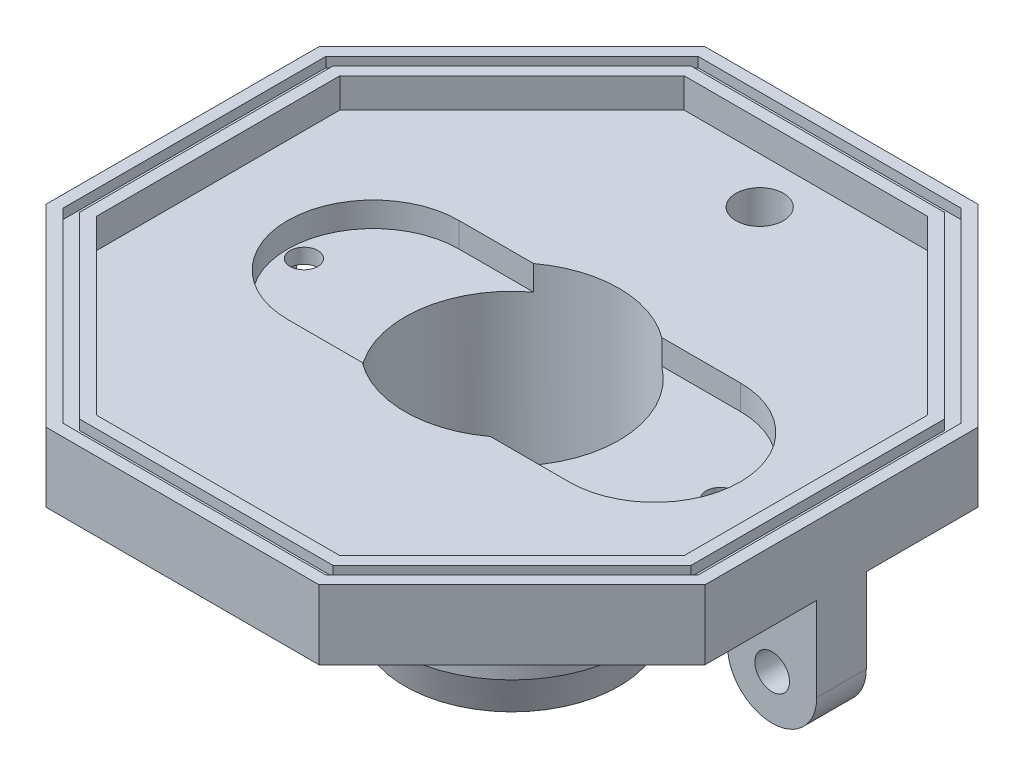
from build123d import *

# Parameters (mm, degrees)
EXTRUDE_1_DEPTH      = 4
SKETCH_2_R           = 2.4
CUT_EXTRUDE_1_DEPTH  = 4
EXTRUDE_3_DEPTH      = 3
CUT_EXTRUDE_2_DEPTH  = 1
SKETCH_7_R           = 10.8
CUT_EXTRUDE_4_DEPTH  = 4
SKETCH_8_R           = 11.8
SKETCH_8_R_2         = 10.8
EXTRUDE_4_DEPTH      = 16.5
SKETCH_9_R           = 10.8
SKETCH_9_R_2         = 6.05
EXTRUDE_5_DEPTH      = 3.5
CUT_EXTRUDE_5_DEPTH  = 2.5
SKETCH_13_W          = 9
SKETCH_13_H          = 5
EXTRUDE_7_DEPTH      = 8.5
SKETCH_16_R          = 1.4
CUT_EXTRUDE_8_DEPTH  = 10
SKETCH_19_ONE_SIDE_W = 4.5
SKETCH_19_ONE_SIDE_H = 5
SKETCH_20_R          = 1.75
CUT_EXTRUDE_9_DEPTH  = 36.75966317


with BuildPart() as part:
    # 스케치1 → 보스-돌출1 (new body)
    with BuildSketch(Plane(origin=(0, 0, 0), x_dir=(1, 0, 0), z_dir=(0, 1, 0))):
        Polygon((13.776603565, -33.25966317), (33.25966317, -13.776603565), (33.25966317, 13.776603565), (13.776603565, 33.25966317), (-13.776603565, 33.25966317), (-33.25966317, 13.776603565), (-33.25966317, -13.776603565), (-13.776603565, -33.25966317), align=None)
    extrude(amount=EXTRUDE_1_DEPTH)

    # 스케치2 → 컷-돌출1 (cut)
    with BuildSketch(Plane.XZ):
        with Locations((0, -25)):
            Circle(SKETCH_2_R)
    extrude(amount=-CUT_EXTRUDE_1_DEPTH, mode=Mode.SUBTRACT)

    # 스케치3 → 보스-돌출3 (add)
    with BuildSketch(Plane(origin=(0, 4, 0), x_dir=(1, 0, 0), z_dir=(0, 1, 0))):
        Polygon((-13.776603565, 33.25966317), (-33.25966317, 13.776603565), (-33.25966317, -13.776603565), (-13.776603565, -33.25966317), (13.776603565, -33.25966317), (33.25966317, -13.776603565), (33.25966317, 13.776603565), (13.776603565, 33.25966317), align=None)
        Polygon((-12.285434741, 29.65966317), (-29.65966317, 12.285434741), (-29.65966317, -12.285434741), (-12.285434741, -29.65966317), (12.285434741, -29.65966317), (29.65966317, -12.285434741), (29.65966317, 12.285434741), (12.285434741, 29.65966317), align=None, mode=Mode.SUBTRACT)
    extrude(amount=EXTRUDE_3_DEPTH)

    # 스케치5 → 컷-돌출2 (cut)
    with BuildSketch(Plane(origin=(0, 7, 0), x_dir=(1, 0, 0), z_dir=(0, 1, 0))):
        Polygon((32.05966317, -13.27954729), (32.05966317, 13.27954729), (13.27954729, 32.05966317), (-13.27954729, 32.05966317), (-32.05966317, 13.27954729), (-32.05966317, -13.27954729), (-13.27954729, -32.05966317), (13.27954729, -32.05966317), align=None)
        Polygon((30.85966317, 12.782491015), (12.782491015, 30.85966317), (-12.782491015, 30.85966317), (-30.85966317, 12.782491015), (-30.85966317, -12.782491015), (-12.782491015, -30.85966317), (12.782491015, -30.85966317), (30.85966317, -12.782491015), align=None, mode=Mode.SUBTRACT)
    extrude(amount=-CUT_EXTRUDE_2_DEPTH, mode=Mode.SUBTRACT)

    # 스케치7 → 컷-돌출4 (cut)
    with BuildSketch(Plane.XZ):
        Circle(SKETCH_7_R)
    extrude(amount=-CUT_EXTRUDE_4_DEPTH, mode=Mode.SUBTRACT)

    # 스케치8 → 보스-돌출4 (add)
    with BuildSketch(Plane.XZ):
        Circle(SKETCH_8_R)
        Circle(SKETCH_8_R_2, mode=Mode.SUBTRACT)
    extrude(amount=EXTRUDE_4_DEPTH)



with BuildPart() as body_2:
    # 스케치9 → 보스-돌출5 (new body)
    with BuildSketch(Plane.XZ.offset(16.5)):
        Circle(SKETCH_9_R)
        Circle(SKETCH_9_R_2, mode=Mode.SUBTRACT)
    extrude(amount=EXTRUDE_5_DEPTH)


with BuildPart() as part_1:
    add(part.part)

    add(body_2.part)  # 회전1 merges body 2
    # 스케치10 → 회전1 (revolve)
    with BuildSketch(Plane.XY):
        Polygon((-11.8, -16.5), (-10.8, -20), (-10.8, -16.5), align=None)
    revolve(axis=Axis((0, -20, 0), (0, 1, 0)))

    # 스케치11 → 컷-돌출5 (cut)
    with BuildSketch(Plane(origin=(0, 4, 0), x_dir=(1, 0, 0), z_dir=(0, 1, 0))):
        with BuildLine():
            Line((-14, 8.65), (14.4, 8.65))
            ThreePointArc((14.4, 8.65), (23.05, 0), (14.4, -8.65))
            Line((14.4, -8.65), (-14, -8.65))
            ThreePointArc((-14, -8.65), (-22.65, 0), (-14, 8.65))
        make_face()
    extrude(amount=-CUT_EXTRUDE_5_DEPTH, mode=Mode.SUBTRACT)

    # 스케치13 → 보스-돌출7 (add)
    with BuildSketch(Plane.XZ):
        with Locations((-28.75966317, 0)):
            Rectangle(SKETCH_13_W, SKETCH_13_H)
    extrude_7 = extrude(amount=EXTRUDE_7_DEPTH)

    # 스케치16 → 컷-돌출8 (cut)
    with BuildSketch(Plane(origin=(0, 1.5, 0), x_dir=(1, 0, 0), z_dir=(0, 1, 0))):
        with Locations((-21, 0)):
            Circle(SKETCH_16_R)
    cut_extrude_8 = extrude(amount=-CUT_EXTRUDE_8_DEPTH, mode=Mode.SUBTRACT)

    # 대칭 복사2: 컷-돌출8 across plane
    add(cut_extrude_8.mirror(Plane(origin=(0, 0, 0), x_dir=(0, 0, 1), z_dir=(1, 0, 0))), mode=Mode.SUBTRACT)

    # 스케치19 one side → 회전2 (revolve)
    with BuildSketch(Plane.XZ.offset(8.5)):
        with Locations((-26.50966317, 0)):
            Rectangle(SKETCH_19_ONE_SIDE_W, SKETCH_19_ONE_SIDE_H)
    revolve_2 = revolve(axis=Axis((-28.75966317, -8.5, 5.440491611), (0, 0, -1)))

    # 스케치20 → 컷-돌출9 (cut, through all)
    with BuildSketch(Plane(origin=(0, 0, -2.5), x_dir=(-1, 0, 0), z_dir=(0, 0, -1))):
        with Locations((28.75966317, -8.5)):
            Circle(SKETCH_20_R)
    cut_extrude_9 = extrude(amount=-CUT_EXTRUDE_9_DEPTH, mode=Mode.SUBTRACT)

    # 대칭 복사3: 보스-돌출7, 회전2, 컷-돌출9 across plane
    add(extrude_7.mirror(Plane(origin=(0, 0, 0), x_dir=(0, 0, 1), z_dir=(1, 0, 0))))
    add(revolve_2.mirror(Plane(origin=(0, 0, 0), x_dir=(0, 0, 1), z_dir=(1, 0, 0))))
    add(cut_extrude_9.mirror(Plane(origin=(0, 0, 0), x_dir=(0, 0, 1), z_dir=(1, 0, 0))), mode=Mode.SUBTRACT)


solid = part_1.part
